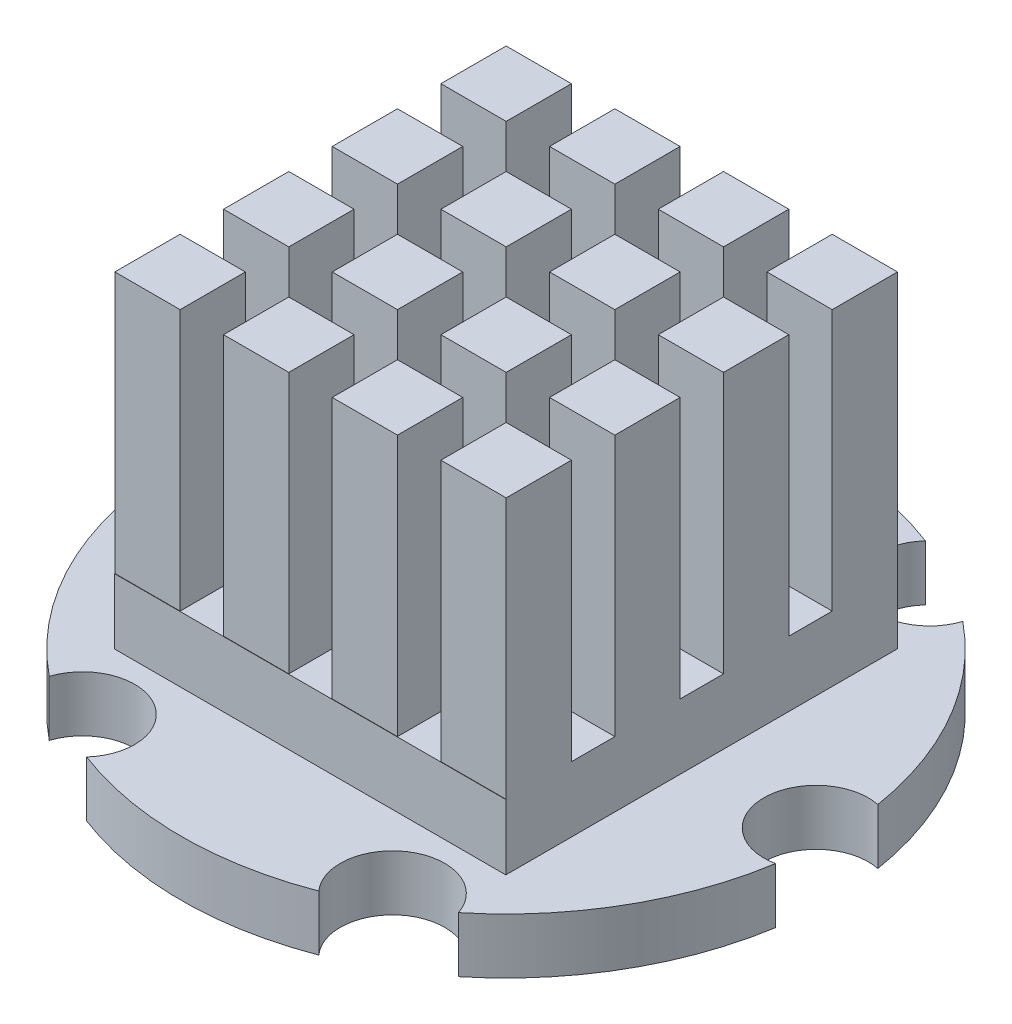
from build123d import *

# Parameters (mm, degrees)
SKETCH1_R           = 9.95
BOSS_EXTRUDE1_DEPTH = 1.7
SKETCH2_R           = 1.6
CUT_EXTRUDE1_DEPTH  = 2.7
SKETCH3_W           = 11.99
SKETCH3_H           = 12
BOSS_EXTRUDE2_DEPTH = 2
SKETCH4_W           = 2
SKETCH4_H           = 2
BOSS_EXTRUDE4_DEPTH = 8
SKETCH5_W           = 5.41
SKETCH5_H           = 5.41
BOSS_EXTRUDE5_DEPTH = 1.1
SKETCH6_R           = 2
BOSS_EXTRUDE6_DEPTH = 0.1
REVOLVE1_ANGLE      = 180


with BuildPart() as part:
    # Sketch1 → Boss-Extrude1 (new body)
    with BuildSketch(Plane(origin=(0, 0, 0), x_dir=(1, 0, 0), z_dir=(0, 1, 0))):
        Circle(SKETCH1_R)
    extrude(amount=BOSS_EXTRUDE1_DEPTH)

    # Sketch2 → Cut-Extrude1 (cut, through all)
    with BuildSketch(Plane(origin=(0, 1.7, 0), x_dir=(1, 0, 0), z_dir=(0, 1, 0))):
        with Locations((9.5, 0)):
            Circle(SKETCH2_R)
        with Locations((4.75, -8.227241336)):
            Circle(SKETCH2_R)
        with Locations((-4.75, -8.227241336)):
            Circle(SKETCH2_R)
        with Locations((-9.5, 0)):
            Circle(SKETCH2_R)
        with Locations((-4.75, 8.227241336)):
            Circle(SKETCH2_R)
        with Locations((4.75, 8.227241336)):
            Circle(SKETCH2_R)
    extrude(amount=-CUT_EXTRUDE1_DEPTH, mode=Mode.SUBTRACT)

    # Sketch3 → Boss-Extrude2 (add)
    with BuildSketch(Plane(origin=(0, 1.7, 0), x_dir=(1, 0, 0), z_dir=(0, 1, 0))):
        Rectangle(SKETCH3_W, SKETCH3_H)
    extrude(amount=BOSS_EXTRUDE2_DEPTH)

    # Sketch4 → Boss-Extrude4 (add)
    with BuildSketch(Plane(origin=(0, 3.7, 0), x_dir=(1, 0, 0), z_dir=(0, 1, 0))):
        with Locations((4.995, 5)):
            Rectangle(SKETCH4_W, SKETCH4_H)
        with Locations((1.665, 5)):
            Rectangle(SKETCH4_W, SKETCH4_H)
        with Locations((-1.665, 5)):
            Rectangle(SKETCH4_W, SKETCH4_H)
        with Locations((-4.995, 5)):
            Rectangle(SKETCH4_W, SKETCH4_H)
        with Locations((1.665, 1.67)):
            Rectangle(SKETCH4_W, SKETCH4_H)
        with Locations((-1.665, 1.67)):
            Rectangle(SKETCH4_W, SKETCH4_H)
        with Locations((-4.995, 1.67)):
            Rectangle(SKETCH4_W, SKETCH4_H)
        with Locations((1.665, -1.66)):
            Rectangle(SKETCH4_W, SKETCH4_H)
        with Locations((-1.665, -1.66)):
            Rectangle(SKETCH4_W, SKETCH4_H)
        with Locations((-4.995, -1.66)):
            Rectangle(SKETCH4_W, SKETCH4_H)
        with Locations((1.665, -4.99)):
            Rectangle(SKETCH4_W, SKETCH4_H)
        with Locations((-1.665, -4.99)):
            Rectangle(SKETCH4_W, SKETCH4_H)
        with Locations((-4.995, -4.99)):
            Rectangle(SKETCH4_W, SKETCH4_H)
        with Locations((4.995, 1.67)):
            Rectangle(SKETCH4_W, SKETCH4_H)
        with Locations((4.995, -1.66)):
            Rectangle(SKETCH4_W, SKETCH4_H)
        with Locations((4.995, -4.99)):
            Rectangle(SKETCH4_W, SKETCH4_H)
    extrude(amount=BOSS_EXTRUDE4_DEPTH)

    # Sketch5 → Boss-Extrude5 (add)
    with BuildSketch(Plane(origin=(0, 0, 0), x_dir=(-1, 0, 0), z_dir=(0, -1, 0))):
        Rectangle(SKETCH5_W, SKETCH5_H)
    extrude(amount=BOSS_EXTRUDE5_DEPTH)

    # Sketch6 → Boss-Extrude6 (add)
    with BuildSketch(Plane.XZ.offset(1.1)):
        Circle(SKETCH6_R)
    extrude(amount=BOSS_EXTRUDE6_DEPTH)

    # Sketch7 → Revolve1 (revolve)
    with BuildSketch(Plane(origin=(0, -1.2, 0), x_dir=(-1, 0, 0), z_dir=(0, -1, 0))):
        with BuildLine():
            Line((0, 1.6), (0, -1.6))
            ThreePointArc((0, -1.6), (-1.6, 0), (0, 1.6))
        make_face()
    revolve(axis=Axis((0, -1.2, -1.6), (0, 0, -1)), revolution_arc=REVOLVE1_ANGLE)


solid = part.part
